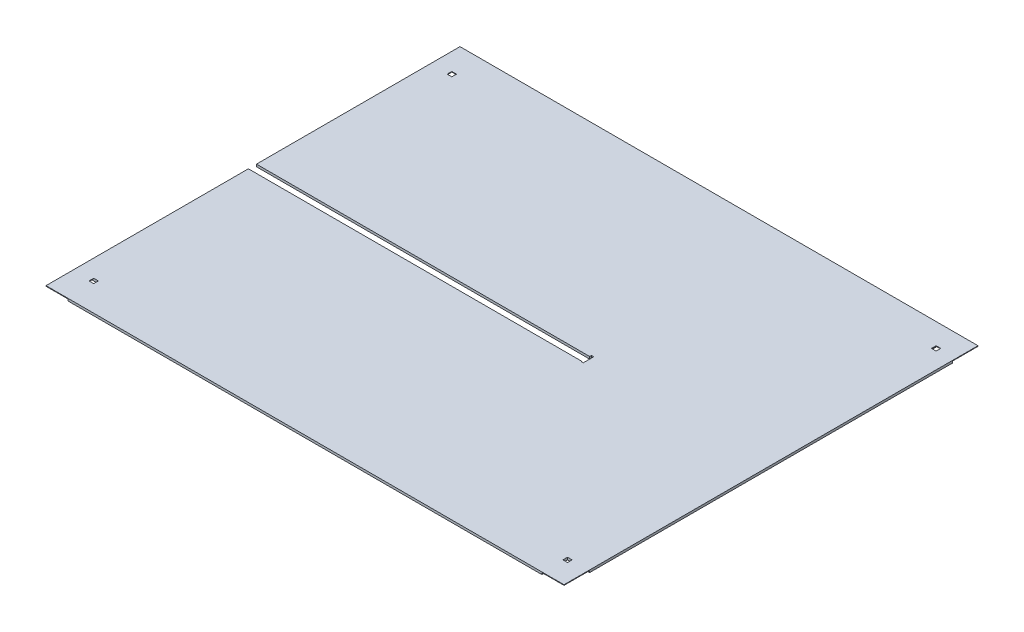
from build123d import *

# Parameters (mm, degrees)
BOSS_EXTRUDE1_DEPTH = 12.7
SKETCH3_W           = 139.7
SKETCH3_H           = 9.525
CUT_EXTRUDE2_DEPTH  = 146.05
SKETCH4_W           = 165.1
SKETCH4_H           = 9.525
CUT_EXTRUDE3_DEPTH  = 120.65
SKETCH5_W           = 25.4
SKETCH5_H           = 25.4
CUT_EXTRUDE4_DEPTH  = 3.175
SKETCH6_W           = 25.4
SKETCH6_H           = 2260.6
CUT_EXTRUDE5_DEPTH  = 12.7


with BuildPart() as part:
    # Sketch1 → Boss-Extrude1 (new body)
    with BuildSketch(Plane(origin=(0, 0, 0), x_dir=(1, 0, 0), z_dir=(0, 1, 0))):
        Polygon((1427.099, -1130.3), (-1427.099, -1130.3), (-1427.099, -25.146), (392.049, -25.146), (392.049, -28.448), (404.749, -28.448), (404.749, 28.702), (392.049, 28.702), (392.049, 19.05), (-1427.099, 19.05), (-1427.099, 1130.3), (1427.099, 1130.3), align=None)
    extrude(amount=BOSS_EXTRUDE1_DEPTH)

    # Sketch3 → Cut-Extrude2 (cut)
    with BuildSketch(Plane(origin=(1427.099, 0, 0), x_dir=(0, 0, -1), z_dir=(1, 0, 0))):
        with Locations((-1060.45, 4.7625)):
            Rectangle(SKETCH3_W, SKETCH3_H)
        with Locations((1060.45, 4.7625)):
            Rectangle(SKETCH3_W, SKETCH3_H)
    extrude(amount=-CUT_EXTRUDE2_DEPTH, mode=Mode.SUBTRACT)

    # Sketch4 → Cut-Extrude3 (cut)
    with BuildSketch(Plane.ZY.offset(1427.099)):
        with Locations((1047.75, 4.7625)):
            Rectangle(SKETCH4_W, SKETCH4_H)
        with Locations((-1047.75, 4.7625)):
            Rectangle(SKETCH4_W, SKETCH4_H)
    extrude(amount=-CUT_EXTRUDE3_DEPTH, mode=Mode.SUBTRACT)

    # Sketch5 → Cut-Extrude4 (cut)
    with BuildSketch(Plane.XZ.offset(-9.525)):
        with Locations((-1319.149, 977.9)):
            Rectangle(SKETCH5_W, SKETCH5_H)
        with Locations((-1319.149, -977.9)):
            Rectangle(SKETCH5_W, SKETCH5_H)
        with Locations((1300.099, -1003.3)):
            Rectangle(SKETCH5_W, SKETCH5_H)
        with Locations((1293.749, 1003.3)):
            Rectangle(SKETCH5_W, SKETCH5_H)
    extrude(amount=-CUT_EXTRUDE4_DEPTH, mode=Mode.SUBTRACT)

    # Sketch6 → Cut-Extrude5 (cut)
    with BuildSketch(Plane(origin=(0, 12.7, 0), x_dir=(1, 0, 0), z_dir=(0, 1, 0))):
        with Locations((1414.399, 0)):
            Rectangle(SKETCH6_W, SKETCH6_H)
    extrude(amount=-CUT_EXTRUDE5_DEPTH, mode=Mode.SUBTRACT)


solid = part.part
